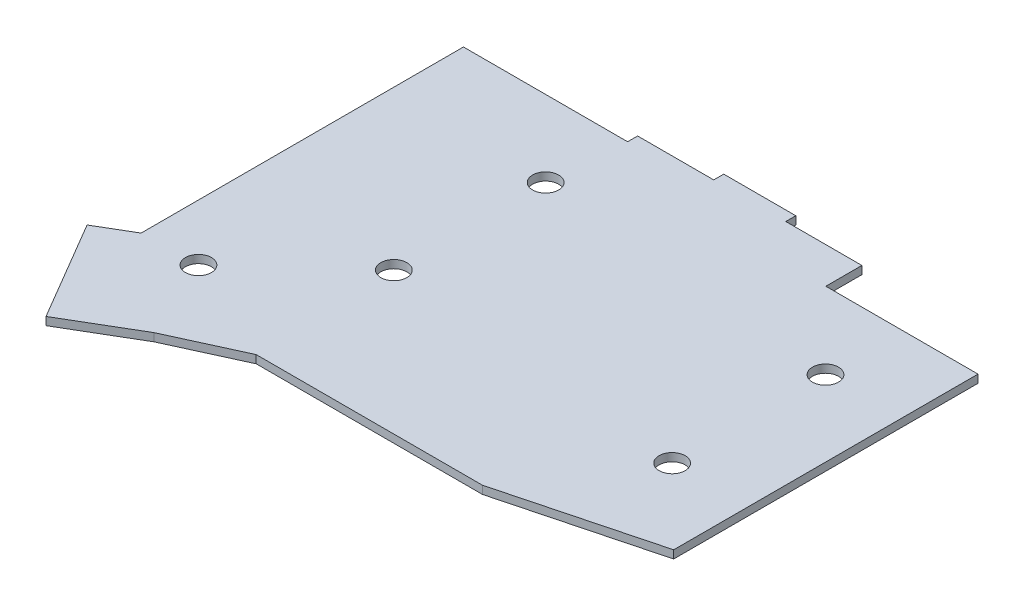
from build123d import *

# Parameters (mm, degrees)
SKETCH_1_R      = 3.25
EXTRUDE_1_DEPTH = 2


with BuildPart() as part:
    # Эскиз1 → Бобышка-Вытянуть1 (new body)
    with BuildSketch(Plane(origin=(0, 0, 0), x_dir=(1, 0, 0), z_dir=(0, 1, 0))):
        Polygon((0, 0), (0, -80.5), (-8.5, -85.5), (6.153232532, -110.410495305), (23.153232532, -100.410495305), (40.653232532, -92.410495305), (97.153232532, -92.410495305), (135, -82.5), (135, -6.5), (97, -6.5), (97, 2.5), (78, 2.5), (78, 5), (60, 5), (60, 2.5), (41, 2.5), (41, 0), align=None)
        with Locations((14.07, -80.258)):
            Circle(SKETCH_1_R, mode=Mode.SUBTRACT)
        with Locations((39.57, -56.958)):
            Circle(SKETCH_1_R, mode=Mode.SUBTRACT)
        with Locations((116.07, -63.958)):
            Circle(SKETCH_1_R, mode=Mode.SUBTRACT)
        with Locations((116.07, -25.658)):
            Circle(SKETCH_1_R, mode=Mode.SUBTRACT)
        with Locations((39.57, -19.048)):
            Circle(SKETCH_1_R, mode=Mode.SUBTRACT)
    extrude(amount=EXTRUDE_1_DEPTH)


solid = part.part
